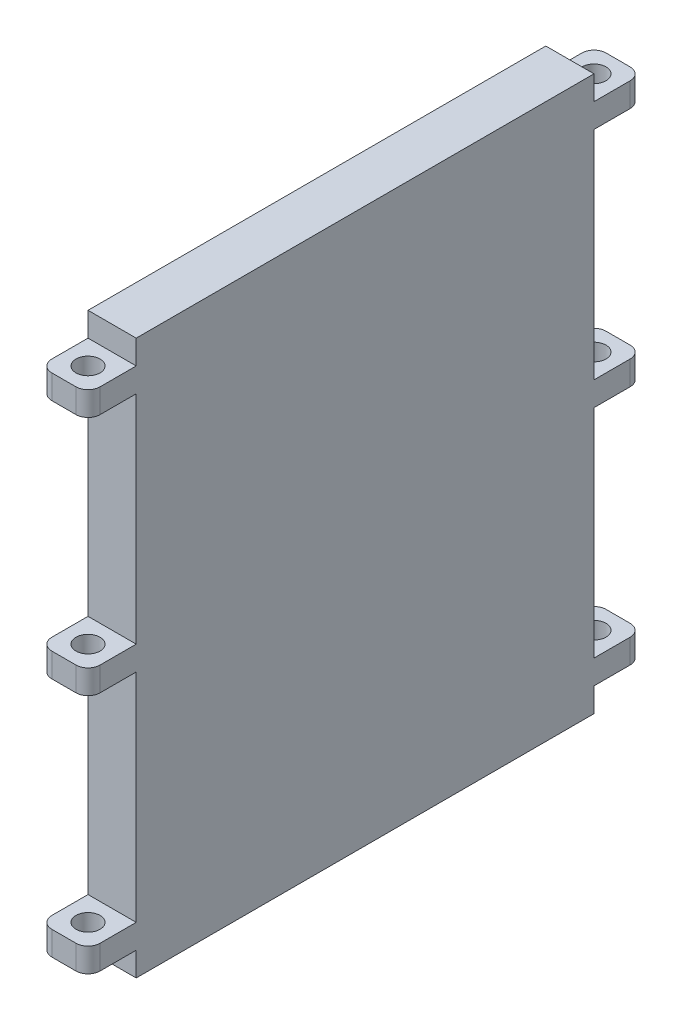
from build123d import *

# Parameters (mm, degrees)
SKETCH1_W           = 230
SKETCH1_H           = 230
BOSS_EXTRUDE1_DEPTH = 20
SKETCH2_W           = 20
SKETCH2_H           = 10
SKETCH2_H_2         = 90
CUT_EXTRUDE1_DEPTH  = 20
SKETCH3_R           = 5
CUT_EXTRUDE2_DEPTH  = 210
FILLET1_R           = 5
FILLET2_R           = 5


with BuildPart() as part:
    # Sketch1 → Boss-Extrude1 (new body)
    with BuildSketch(Plane(origin=(0, 0, 0), x_dir=(0, 0, -1), z_dir=(1, 0, 0))):
        Rectangle(SKETCH1_W, SKETCH1_H)
    extrude(amount=BOSS_EXTRUDE1_DEPTH)

    # Sketch2 → Cut-Extrude1 (cut)
    with BuildSketch(Plane.XY.offset(115)):
        with Locations((10, 110)):
            Rectangle(SKETCH2_W, SKETCH2_H)
        with Locations((10, 50)):
            Rectangle(SKETCH2_W, SKETCH2_H_2)
        with Locations((10, -50)):
            Rectangle(SKETCH2_W, SKETCH2_H_2)
        with Locations((10, -110)):
            Rectangle(SKETCH2_W, SKETCH2_H)
    cut_extrude1 = extrude(amount=-CUT_EXTRUDE1_DEPTH, mode=Mode.SUBTRACT)

    # Sketch3 → Cut-Extrude2 (cut)
    with BuildSketch(Plane(origin=(0, 105, 0), x_dir=(1, 0, 0), z_dir=(0, 1, 0))):
        with Locations((10, -105)):
            Circle(SKETCH3_R)
    cut_extrude2 = extrude(amount=-CUT_EXTRUDE2_DEPTH, mode=Mode.SUBTRACT)

    # Fillet1
    fillet1_edges = [part.edges().sort_by_distance(p)[0] for p in [
        (0, 100, 115),
        (0, 0, 115),
        (0, -100, 115),
        (20, 100, 115),
        (20, 0, 115),
        (20, -100, 115),
    ]]
    fillet(fillet1_edges, radius=FILLET1_R)

    # Mirror5: Cut-Extrude1, Cut-Extrude2 across plane
    add(cut_extrude1.mirror(Plane.XY), mode=Mode.SUBTRACT)
    add(cut_extrude2.mirror(Plane.XY), mode=Mode.SUBTRACT)

    # Fillet2
    fillet2_edges = [part.edges().sort_by_distance(p)[0] for p in [
        (0, -100, -115),
        (0, 0, -115),
        (0, 100, -115),
        (20, -100, -115),
        (20, 0, -115),
        (20, 100, -115),
    ]]
    fillet(fillet2_edges, radius=FILLET2_R)


solid = part.part
